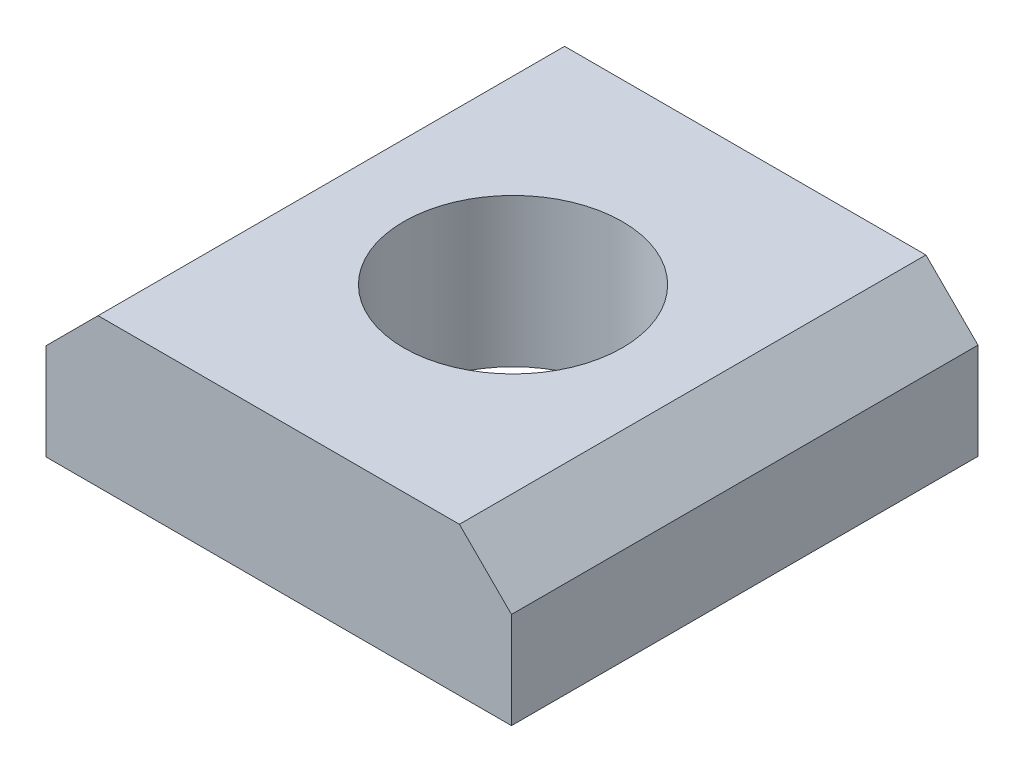
from build123d import *

# Parameters (mm, degrees)
SKETCH1_W                 = 8.94
SKETCH1_H                 = 8.96
EXTRUDE1_DEPTH            = 2.85
M5X0_8_TAPPED_HOLE1_D     = 4.2
M5X0_8_TAPPED_HOLE1_DEPTH = 12.4
M5X0_8_TAPPED_HOLE1_TIP   = 1.2618073
CHAMFER1_SIZE             = 1


with BuildPart() as part:
    # Sketch1 → Extrude1 (new body)
    with BuildSketch(Plane(origin=(0, 0, 0), x_dir=(1, 0, 0), z_dir=(0, 1, 0))):
        with Locations((0, -0.02)):
            Rectangle(SKETCH1_W, SKETCH1_H)
    extrude(amount=EXTRUDE1_DEPTH)

    # M5x0.8 Tapped Hole1
    with Locations(Plane(origin=(0, 2.85, 0), x_dir=(1, 0, 0), z_dir=(0, 1, 0))):
        with Locations((0, 0)):
            Hole(M5X0_8_TAPPED_HOLE1_D / 2, depth=M5X0_8_TAPPED_HOLE1_DEPTH)
            with Locations((0, 0, -(M5X0_8_TAPPED_HOLE1_DEPTH + M5X0_8_TAPPED_HOLE1_TIP / 2))):  # 118° drill point
                Cone(0, M5X0_8_TAPPED_HOLE1_D / 2, M5X0_8_TAPPED_HOLE1_TIP, mode=Mode.SUBTRACT)

    # Chamfer1
    chamfer1_edges = [part.edges().sort_by_distance(p)[0] for p in [
        (4.47, 2.85, 0.02),
        (-4.47, 2.85, 0.02),
    ]]
    chamfer(chamfer1_edges, length=CHAMFER1_SIZE)


solid = part.part
